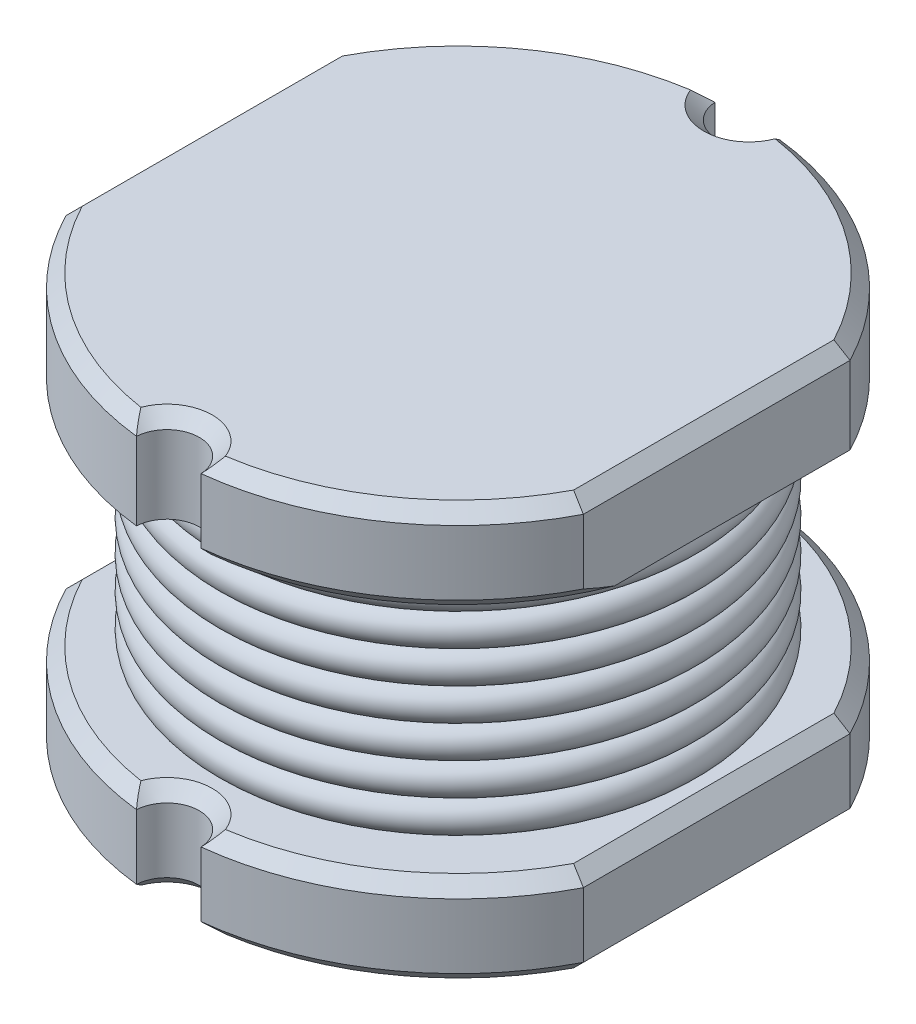
from build123d import *

# Parameters (mm, degrees)
SKETCH1_R                 = 2.25
BASE_DEPTH                = 0.7
SKETCH2_R                 = 1.5
COIL_ENCOMPASSMENT_DEPTH  = 1.8
SKETCH3_R                 = 2.25
TOP_BASE_DEPTH            = 0.7
SKETCH5_R                 = 0.25
SIDE_CUTS_FOR_BASES_DEPTH = 3.2
SKETCH98_W                = 0.25
SKETCH98_H                = 2.061552812
BASE_SIDES_DEPTH          = 4.2
COIL_PROFILE_R            = 0.125
COIL_P_COUNT              = 7
COIL_P_PITCH              = 0.25
BASES_C_SIZE              = 0.1


with BuildPart() as part:
    # Sketch1 → BASE (new body)
    with BuildSketch(Plane(origin=(0, 0, 0), x_dir=(1, 0, 0), z_dir=(0, 1, 0))):
        Circle(SKETCH1_R)
    extrude(amount=BASE_DEPTH)

    # Sketch2 → COIL ENCOMPASSMENT (add)
    with BuildSketch(Plane(origin=(0, 0.7, 0), x_dir=(1, 0, 0), z_dir=(0, 1, 0))):
        Circle(SKETCH2_R)
    extrude(amount=COIL_ENCOMPASSMENT_DEPTH)

    # Sketch3 → TOP BASE (add)
    with BuildSketch(Plane(origin=(0, 2.5, 0), x_dir=(1, 0, 0), z_dir=(0, 1, 0))):
        Circle(SKETCH3_R)
    extrude(amount=TOP_BASE_DEPTH)

    # Sketch5 → SIDE CUTS FOR BASES (cut)
    with BuildSketch(Plane(origin=(0, 3.2, 0), x_dir=(1, 0, 0), z_dir=(0, 1, 0))):
        with Locations((0, -2.25)):
            Circle(SKETCH5_R)
        with Locations((0, 2.25)):
            Circle(SKETCH5_R)
    extrude(amount=-SIDE_CUTS_FOR_BASES_DEPTH, mode=Mode.SUBTRACT)

    # Sketch98 → BASE SIDES (cut, through all)
    with BuildSketch(Plane(origin=(0, 3.2, 0), x_dir=(1, 0, 0), z_dir=(0, 1, 0))):
        with Locations((-2.125, 0)):
            Rectangle(SKETCH98_W, SKETCH98_H)
    base_sides = extrude(amount=-BASE_SIDES_DEPTH, mode=Mode.SUBTRACT)

    # BS M: BASE SIDES across plane
    add(base_sides.mirror(Plane(origin=(0, 0, 0), x_dir=(0, 0, 1), z_dir=(1, 0, 0))), mode=Mode.SUBTRACT)

    # BASES C
    bases_c_edges = [part.edges().sort_by_distance(p)[0] for p in [
        (1.276087227, 0, 1.853132858),
        (0, 0, 2),
        (0, 3.2, 2),
        (0, 0.7, 2),
        (-1.276087227, 2.5, -1.853132858),
        (-1.276087227, 3.2, -1.853132858),
        (-1.276087227, 0, -1.853132858),
        (-1.276087227, 0.7, -1.853132858),
        (0, 0, -2),
        (0, 3.2, -2),
        (0, 0.7, -2),
        (1.276087227, 0.7, 1.853132858),
        (-1.276087227, 3.2, 1.853132858),
        (-1.276087227, 0, 1.853132858),
        (-1.276087227, 0.7, 1.853132858),
        (-2, 3.2, 0),
        (-2, 0.7, 0),
        (-2, 0, 0),
        (-1.5, 0.7, 0),
        (1.276087227, 3.2, -1.853132858),
        (1.276087227, 0, -1.853132858),
        (1.276087227, 0.7, -1.853132858),
        (2, 0, 0),
        (2, 3.2, 0),
        (2, 0.7, 0),
        (1.276087227, 2.5, 1.853132858),
        (1.276087227, 3.2, 1.853132858),
    ]]
    chamfer(bases_c_edges, length=BASES_C_SIZE)


with BuildPart() as body_2:
    # COIL: sweep along a path in Sketch6
    with BuildLine(Plane(origin=(0, 0.825, 0), x_dir=(1, 0, 0), z_dir=(0, 1, 0))) as coil_path:
        CenterArc((0, 0), 1.75, 0, 360)
    # COIL profile (on start of the path) → COIL (sweep)
    with BuildSketch(Plane(origin=(1.75, 0.825, 0), x_dir=(-1, 0, 0), z_dir=(0, 0, -1))):
        Circle(COIL_PROFILE_R)
    sweep(path=coil_path.line)


with BuildPart() as coil_p_1:
    # COIL P: pattern copy
    add(body_2.part.moved(Location(Vector(0, 1, 0) * (1 * COIL_P_PITCH))))


with BuildPart() as coil_p_2:
    # COIL P: pattern copy
    add(body_2.part.moved(Location(Vector(0, 1, 0) * (2 * COIL_P_PITCH))))


with BuildPart() as coil_p_3:
    # COIL P: pattern copy
    add(body_2.part.moved(Location(Vector(0, 1, 0) * (3 * COIL_P_PITCH))))


with BuildPart() as coil_p_4:
    # COIL P: pattern copy
    add(body_2.part.moved(Location(Vector(0, 1, 0) * (4 * COIL_P_PITCH))))


with BuildPart() as coil_p_5:
    # COIL P: pattern copy
    add(body_2.part.moved(Location(Vector(0, 1, 0) * (5 * COIL_P_PITCH))))


with BuildPart() as coil_p_6:
    # COIL P: pattern copy
    add(body_2.part.moved(Location(Vector(0, 1, 0) * (6 * COIL_P_PITCH))))


solid = Compound([part.part, body_2.part, coil_p_1.part, coil_p_2.part, coil_p_3.part, coil_p_4.part, coil_p_5.part, coil_p_6.part])
